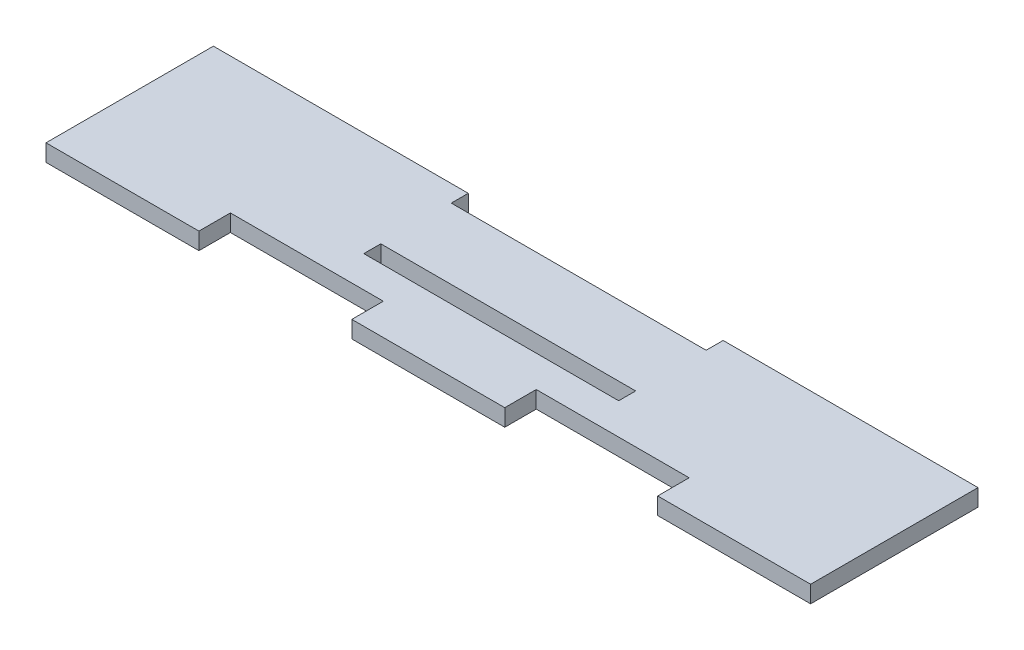
from build123d import *

# Parameters (mm, degrees)
SKETCH1_W           = 40.5
SKETCH1_H           = 2.7
BOSS_EXTRUDE1_DEPTH = 2.7


with BuildPart() as part:
    # Sketch1 → Boss-Extrude1 (new body)
    with BuildSketch(Plane(origin=(0, 0, 0), x_dir=(1, 0, 0), z_dir=(0, 1, 0))):
        Polygon((-60.75, 13.3), (-20.25, 13.3), (-20.25, 10.6), (20.25, 10.6), (20.25, 13.3), (60.75, 13.3), (60.75, -13.3), (36.45, -13.3), (36.45, -8.3), (12.15, -8.3), (12.15, -13.3), (-12.15, -13.3), (-12.15, -8.3), (-36.45, -8.3), (-36.45, -13.3), (-60.75, -13.3), align=None)
        with Locations((0, -1.95)):
            Rectangle(SKETCH1_W, SKETCH1_H, mode=Mode.SUBTRACT)
    extrude(amount=BOSS_EXTRUDE1_DEPTH)


solid = part.part
